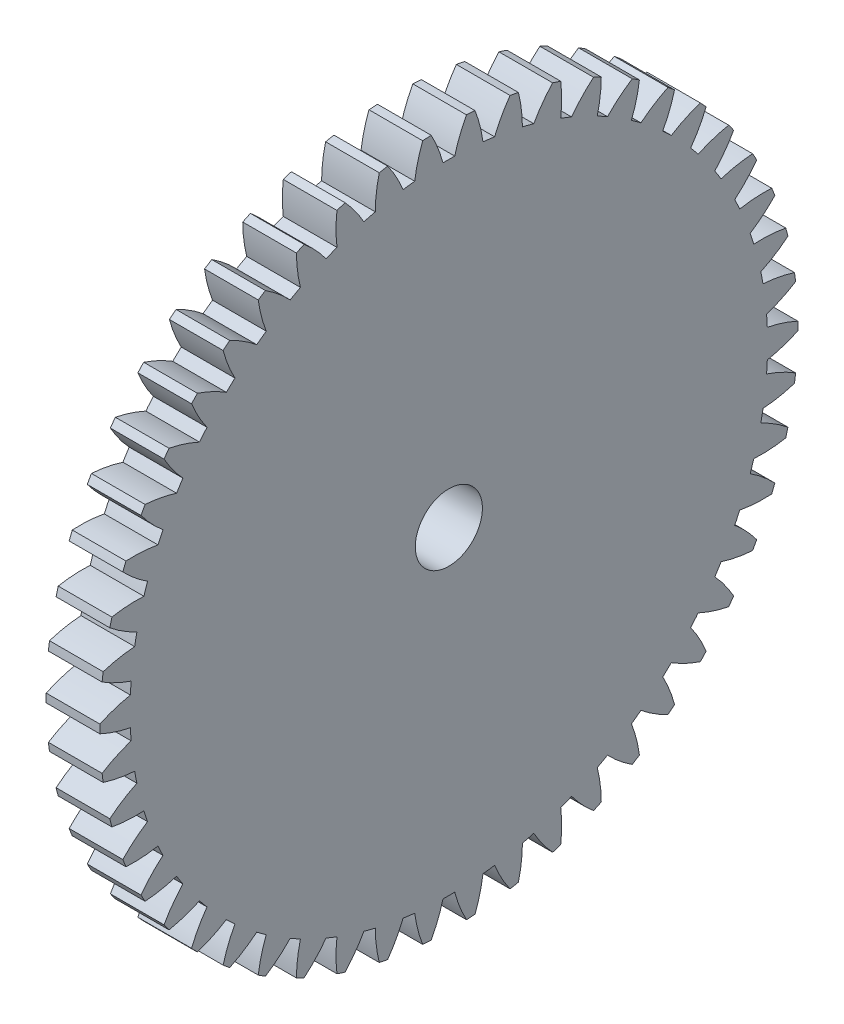
from build123d import *

# Parameters (mm, degrees)
BASPROSKE_W     = 4
BASPROSKE_H     = 26
TOOTHCUT_DEPTH  = 37.986484018
TEETHCUTS_COUNT = 50
TEETHCUTS_ANGLE = 352.8
BORSKE_R        = 2.5
BORE_DEPTH      = 50.0000508


with BuildPart() as part:
    # BasProSke → Base-Revolve (revolve)
    with BuildSketch(Plane(origin=(0, 0, 0), x_dir=(1, 0, 0), z_dir=(0, 1, 0)), mode=Mode.PRIVATE) as base_revolve_sk:
        with Locations((2, 13)):
            Rectangle(BASPROSKE_W, BASPROSKE_H)
    revolve(base_revolve_sk.sketch.rotate(Axis((-10, 0, 0), (1, 0, 0)), 180), axis=Axis((-10, 0, 0), (1, 0, 0)))

    # TooCutSke → ToothCut (cut, through all)
    with BuildSketch(Plane(origin=(0, 0, 0), x_dir=(0, 0, -1), z_dir=(1, 0, 0))):
        with BuildLine():
            ThreePointArc((0.437663408, 23.744966872), (0, 23.749), (-0.437663408, 23.744966872))
            ThreePointArc((-0.437663408, 23.744966872), (-0.815428123, 24.895236298), (-1.329433358, 25.991422664))
            ThreePointArc((-1.329433358, 25.991422664), (0, 26.0254), (1.329433358, 25.991422664))
            ThreePointArc((1.329433358, 25.991422664), (0.815428123, 24.895236298), (0.437663408, 23.744966872))
        make_face()
    toothcut = extrude(amount=TOOTHCUT_DEPTH, mode=Mode.SUBTRACT)

    # TeethCuts: ToothCut ×50 about axis
    teethcuts_axis = Axis((-10, 0, 0), (1, 0, 0))
    for i in range(1, TEETHCUTS_COUNT):
        add(toothcut.rotate(teethcuts_axis, i * TEETHCUTS_ANGLE / (TEETHCUTS_COUNT - 1)), mode=Mode.SUBTRACT)

    # BorSke → Bore (cut, symmetric)
    with BuildSketch(Plane(origin=(0, 0, 0), x_dir=(0, 0, -1), z_dir=(1, 0, 0))):
        with Locations(Location((0, 0, 0), (0, 0, 180))):
            Circle(BORSKE_R)
    extrude(amount=BORE_DEPTH, both=True, mode=Mode.SUBTRACT)


solid = part.part
